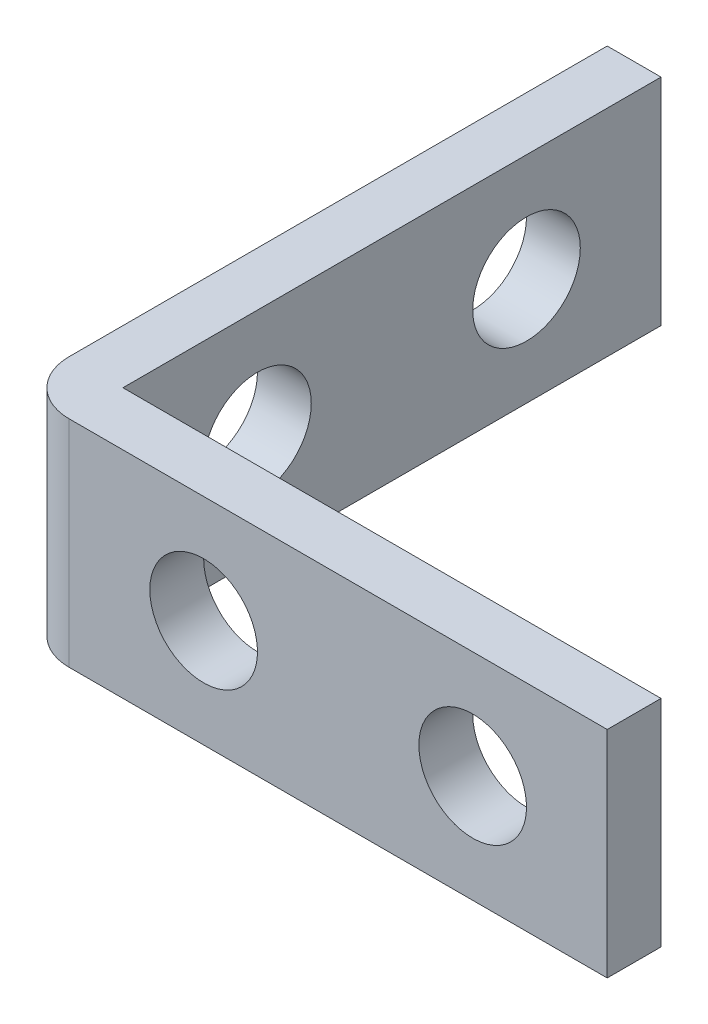
from build123d import *

# Parameters (mm, degrees)
BOSS_EXTRUDE1_DEPTH = 8
SKETCH2_R           = 2
CUT_EXTRUDE1_DEPTH  = 8
SKETCH3_R           = 2
CUT_EXTRUDE2_DEPTH  = 8
FILLET3_R           = 2


with BuildPart() as part:
    # Sketch1 → Boss-Extrude1 (new body)
    with BuildSketch(Plane(origin=(0, 0, 0), x_dir=(1, 0, 0), z_dir=(0, 1, 0))):
        Polygon((0, 20), (0, 0), (20, 0), (20, -2), (-2, -2), (-2, 20), align=None)
    extrude(amount=BOSS_EXTRUDE1_DEPTH)

    # Sketch2 → Cut-Extrude1 (cut)
    with BuildSketch(Plane(origin=(0, 0, 0), x_dir=(-1, 0, 0), z_dir=(0, 0, -1))):
        with Locations((-15, 4)):
            Circle(SKETCH2_R)
        with Locations((-5, 4)):
            Circle(SKETCH2_R)
    extrude(amount=-CUT_EXTRUDE1_DEPTH, mode=Mode.SUBTRACT)

    # Sketch3 → Cut-Extrude2 (cut)
    with BuildSketch(Plane(origin=(0, 0, 0), x_dir=(0, 0, -1), z_dir=(1, 0, 0))):
        with Locations((5, 4)):
            Circle(SKETCH3_R)
        with Locations((15, 4)):
            Circle(SKETCH3_R)
    extrude(amount=-CUT_EXTRUDE2_DEPTH, mode=Mode.SUBTRACT)

    # Fillet3
    fillet3_edges = [part.edges().sort_by_distance(p)[0] for p in [
        (-2, 4, 2),
    ]]
    fillet(fillet3_edges, radius=FILLET3_R)


solid = part.part
